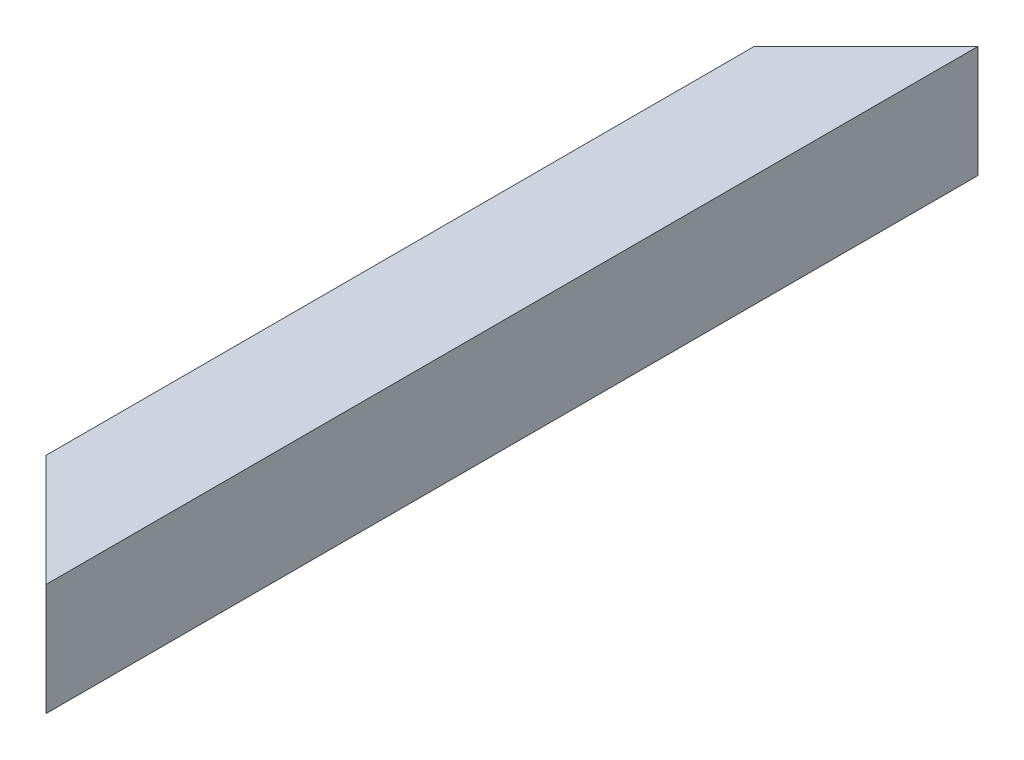
from build123d import *

# Parameters (mm, degrees)
SKETCH1_W          = 60
SKETCH1_H          = 60
SKETCH1_W_2        = 52
SKETCH1_H_2        = 52
CUT_EXTRUDE1_DEPTH = 61.0000001


with BuildPart() as part:
    # Sweep1: sweep along a curve in space
    with BuildLine() as sweep1_path:
        add(Edge.make_bspline(
            [(0, 0, 0), (0, 0, 500)],
            knots=[0, 0, 1, 1], degree=1))
    # Sketch1 → Sweep1 (sweep)
    with BuildSketch(Plane.XY):
        Rectangle(SKETCH1_W, SKETCH1_H)
        Rectangle(SKETCH1_W_2, SKETCH1_H_2, mode=Mode.SUBTRACT)
    sweep(path=sweep1_path.line)

    # Sketch2 → Cut-Extrude1 (cut, through all)
    with BuildSketch(Plane(origin=(0, 30, 0), x_dir=(1, 0, 0), z_dir=(0, 1, 0))):
        Polygon((30, 0), (-30, -60), (-30, 0), align=None)
        Polygon((30, -500), (-30, -440), (-30, -500), align=None)
    extrude(amount=-CUT_EXTRUDE1_DEPTH, mode=Mode.SUBTRACT)


solid = part.part
